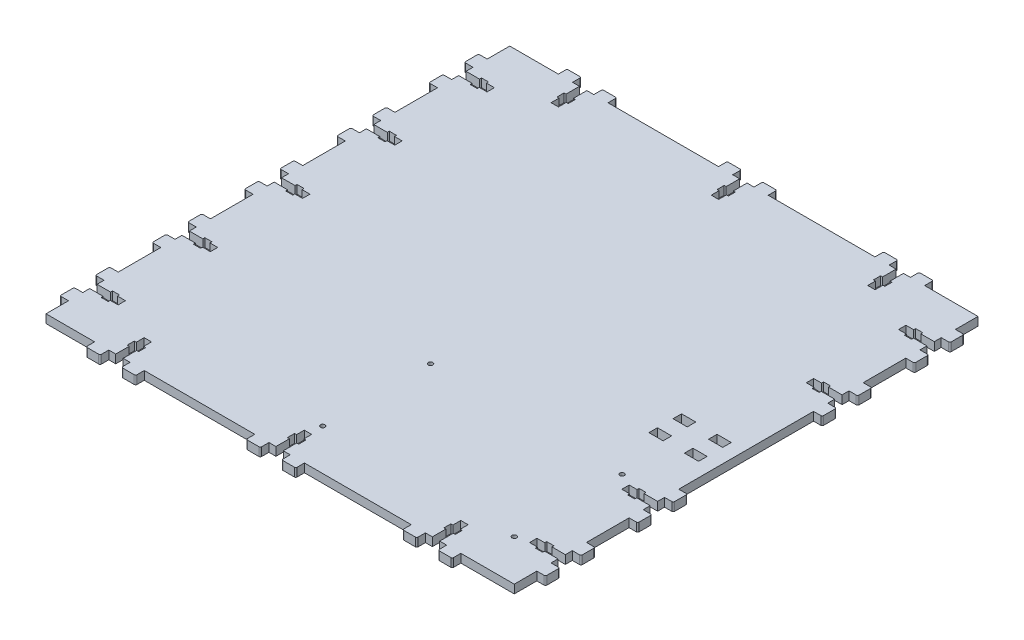
from build123d import *

# Parameters (mm, degrees)
SKETCH1_W                  = 330
SKETCH1_H                  = 326.8
BOSS_EXTRUDE1_DEPTH        = 6
CUT_EXTRUDE2_DEPTH         = 4
CUT_EXTRUDE2_DEPTH_BACK    = 4
SKETCH234_W                = 6.1
SKETCH234_H                = 10
BOSS_EXTRUDE2_DEPTH        = 3
BOSS_EXTRUDE2_DEPTH_BACK   = 3
FILLET1_R                  = 1
CUT_EXTRUDE21_DEPTH        = 4
CUT_EXTRUDE21_DEPTH_BACK   = 4
SKETCH2341_W               = 6.1
SKETCH2341_H               = 10
BOSS_EXTRUDE21_DEPTH       = 3
BOSS_EXTRUDE21_DEPTH_BACK  = 3
FILLET11_R                 = 1
CUT_EXTRUDE22_DEPTH        = 4
CUT_EXTRUDE22_DEPTH_BACK   = 4
SKETCH2342_W               = 6.1
SKETCH2342_H               = 10
BOSS_EXTRUDE22_DEPTH       = 3
BOSS_EXTRUDE22_DEPTH_BACK  = 3
FILLET12_R                 = 1
CUT_EXTRUDE23_DEPTH        = 4
CUT_EXTRUDE23_DEPTH_BACK   = 4
SKETCH2343_W               = 6.1
SKETCH2343_H               = 10
BOSS_EXTRUDE23_DEPTH       = 3
BOSS_EXTRUDE23_DEPTH_BACK  = 3
FILLET13_R                 = 1
CUT_EXTRUDE24_DEPTH        = 4
CUT_EXTRUDE24_DEPTH_BACK   = 4
SKETCH2344_W               = 6.1
SKETCH2344_H               = 10
BOSS_EXTRUDE24_DEPTH       = 3
BOSS_EXTRUDE24_DEPTH_BACK  = 3
FILLET14_R                 = 1
CUT_EXTRUDE25_DEPTH        = 4
CUT_EXTRUDE25_DEPTH_BACK   = 4
SKETCH2345_W               = 6.1
SKETCH2345_H               = 10
BOSS_EXTRUDE25_DEPTH       = 3
BOSS_EXTRUDE25_DEPTH_BACK  = 3
FILLET15_R                 = 1
CUT_EXTRUDE27_DEPTH        = 4
CUT_EXTRUDE27_DEPTH_BACK   = 4
SKETCH2347_W               = 6.1
SKETCH2347_H               = 10
BOSS_EXTRUDE27_DEPTH       = 3
BOSS_EXTRUDE27_DEPTH_BACK  = 3
FILLET17_R                 = 1
CUT_EXTRUDE28_DEPTH        = 4
CUT_EXTRUDE28_DEPTH_BACK   = 4
SKETCH2348_W               = 6.1
SKETCH2348_H               = 10
BOSS_EXTRUDE28_DEPTH       = 3
BOSS_EXTRUDE28_DEPTH_BACK  = 3
FILLET18_R                 = 1
CUT_EXTRUDE29_DEPTH        = 4
CUT_EXTRUDE29_DEPTH_BACK   = 4
SKETCH2349_W               = 6.1
SKETCH2349_H               = 10
BOSS_EXTRUDE29_DEPTH       = 3
BOSS_EXTRUDE29_DEPTH_BACK  = 3
FILLET19_R                 = 1
CUT_EXTRUDE210_DEPTH       = 4
CUT_EXTRUDE210_DEPTH_BACK  = 4
SKETCH23410_W              = 6.1
SKETCH23410_H              = 10
BOSS_EXTRUDE210_DEPTH      = 3
BOSS_EXTRUDE210_DEPTH_BACK = 3
FILLET110_R                = 1
CUT_EXTRUDE211_DEPTH       = 4
CUT_EXTRUDE211_DEPTH_BACK  = 4
SKETCH23411_W              = 6.1
SKETCH23411_H              = 10
BOSS_EXTRUDE211_DEPTH      = 3
BOSS_EXTRUDE211_DEPTH_BACK = 3
FILLET111_R                = 1
CUT_EXTRUDE213_DEPTH       = 4
CUT_EXTRUDE213_DEPTH_BACK  = 4
SKETCH23415_W              = 6.1
SKETCH23415_H              = 10
BOSS_EXTRUDE213_DEPTH      = 3
BOSS_EXTRUDE213_DEPTH_BACK = 3
FILLET113_R                = 1
CUT_EXTRUDE214_DEPTH       = 4
CUT_EXTRUDE214_DEPTH_BACK  = 4
SKETCH23416_W              = 6.1
SKETCH23416_H              = 10
BOSS_EXTRUDE214_DEPTH      = 3
BOSS_EXTRUDE214_DEPTH_BACK = 3
FILLET114_R                = 1
CUT_EXTRUDE216_DEPTH       = 4
CUT_EXTRUDE216_DEPTH_BACK  = 4
SKETCH23420_W              = 6.1
SKETCH23420_H              = 10
BOSS_EXTRUDE216_DEPTH      = 3
BOSS_EXTRUDE216_DEPTH_BACK = 3
FILLET116_R                = 1
CUT_EXTRUDE217_DEPTH       = 4
CUT_EXTRUDE217_DEPTH_BACK  = 4
SKETCH23422_W              = 6.1
SKETCH23422_H              = 10
BOSS_EXTRUDE217_DEPTH      = 3
BOSS_EXTRUDE217_DEPTH_BACK = 3
FILLET117_R                = 1
SKETCH6_W                  = 10
SKETCH6_H                  = 6
CUT_EXTRUDE1_DEPTH         = 4
SKETCH61_W                 = 10
SKETCH61_H                 = 6
CUT_EXTRUDE11_DEPTH        = 4
M3_CLEARANCE_HOLE1_D       = 3.2


with BuildPart() as part:
    # Sketch1 → Boss-Extrude1 (new body)
    with BuildSketch(Plane(origin=(0, 0, 0), x_dir=(1, 0, 0), z_dir=(0, 1, 0))):
        Rectangle(SKETCH1_W, SKETCH1_H)
    extrude(amount=BOSS_EXTRUDE1_DEPTH)

    # Sketch23 → Cut-Extrude2 (cut, two sides)
    with BuildSketch(Plane(origin=(-93.25, 3, 113.4), x_dir=(0, 0, 1), z_dir=(0, -1, 0))) as cut_extrude2_sk:
        Polygon((30, 17.4), (30, 22.6), (35.5, 22.6), (35.5, 24), (40.5, 24), (40.5, 22.6), (50, 22.6), (50, 17.4), (40.5, 17.4), (40.5, 16), (35.5, 16), (35.5, 17.4), align=None)
    extrude(amount=CUT_EXTRUDE2_DEPTH, mode=Mode.SUBTRACT)
    extrude(cut_extrude2_sk.sketch, amount=-CUT_EXTRUDE2_DEPTH_BACK, mode=Mode.SUBTRACT)

    # Sketch234 → Boss-Extrude2 (add, two sides)
    with BuildSketch(Plane(origin=(-93.25, 3, 113.4), x_dir=(0, 0, 1), z_dir=(0, -1, 0))) as boss_extrude2_sk:
        with Locations((53.05, 32.5)):
            Rectangle(SKETCH234_W, SKETCH234_H)
        with Locations((53.05, 7.5)):
            Rectangle(SKETCH234_W, SKETCH234_H)
    extrude(amount=BOSS_EXTRUDE2_DEPTH)
    extrude(boss_extrude2_sk.sketch, amount=-BOSS_EXTRUDE2_DEPTH_BACK)

    # Fillet1
    fillet1_edges = [part.edges().sort_by_distance(p)[0] for p in [
        (-130.75, 3, 169.5),
        (-120.75, 3, 169.5),
        (-105.75, 3, 169.5),
        (-95.75, 3, 169.5),
    ]]
    fillet(fillet1_edges, radius=FILLET1_R)

    # Sketch236 → Cut-Extrude21 (cut, two sides)
    with BuildSketch(Plane(origin=(19.625, 3, 113.4), x_dir=(0, 0, 1), z_dir=(0, -1, 0))) as cut_extrude21_sk:
        Polygon((30, 17.4), (30, 22.6), (35.5, 22.6), (35.5, 24), (40.5, 24), (40.5, 22.6), (50, 22.6), (50, 17.4), (40.5, 17.4), (40.5, 16), (35.5, 16), (35.5, 17.4), align=None)
    extrude(amount=CUT_EXTRUDE21_DEPTH, mode=Mode.SUBTRACT)
    extrude(cut_extrude21_sk.sketch, amount=-CUT_EXTRUDE21_DEPTH_BACK, mode=Mode.SUBTRACT)

    # Sketch2341 → Boss-Extrude21 (add, two sides)
    with BuildSketch(Plane(origin=(19.625, 3, 113.4), x_dir=(0, 0, 1), z_dir=(0, -1, 0))) as boss_extrude21_sk:
        with Locations((53.05, 32.5)):
            Rectangle(SKETCH2341_W, SKETCH2341_H)
        with Locations((53.05, 7.5)):
            Rectangle(SKETCH2341_W, SKETCH2341_H)
    extrude(amount=BOSS_EXTRUDE21_DEPTH)
    extrude(boss_extrude21_sk.sketch, amount=-BOSS_EXTRUDE21_DEPTH_BACK)

    # Fillet11
    fillet11_edges = [part.edges().sort_by_distance(p)[0] for p in [
        (-17.875, 3, 169.5),
        (-7.875, 3, 169.5),
        (7.125, 3, 169.5),
        (17.125, 3, 169.5),
    ]]
    fillet(fillet11_edges, radius=FILLET11_R)

    # Sketch237 → Cut-Extrude22 (cut, two sides)
    with BuildSketch(Plane(origin=(129.875, 3, 113.4), x_dir=(0, 0, 1), z_dir=(0, -1, 0))) as cut_extrude22_sk:
        Polygon((30, 17.4), (30, 22.6), (35.5, 22.6), (35.5, 24), (40.5, 24), (40.5, 22.6), (50, 22.6), (50, 17.4), (40.5, 17.4), (40.5, 16), (35.5, 16), (35.5, 17.4), align=None)
    extrude(amount=CUT_EXTRUDE22_DEPTH, mode=Mode.SUBTRACT)
    extrude(cut_extrude22_sk.sketch, amount=-CUT_EXTRUDE22_DEPTH_BACK, mode=Mode.SUBTRACT)

    # Sketch2342 → Boss-Extrude22 (add, two sides)
    with BuildSketch(Plane(origin=(129.875, 3, 113.4), x_dir=(0, 0, 1), z_dir=(0, -1, 0))) as boss_extrude22_sk:
        with Locations((53.05, 32.5)):
            Rectangle(SKETCH2342_W, SKETCH2342_H)
        with Locations((53.05, 7.5)):
            Rectangle(SKETCH2342_W, SKETCH2342_H)
    extrude(amount=BOSS_EXTRUDE22_DEPTH)
    extrude(boss_extrude22_sk.sketch, amount=-BOSS_EXTRUDE22_DEPTH_BACK)

    # Fillet12
    fillet12_edges = [part.edges().sort_by_distance(p)[0] for p in [
        (92.375, 3, 169.5),
        (102.375, 3, 169.5),
        (117.375, 3, 169.5),
        (127.375, 3, 169.5),
    ]]
    fillet(fillet12_edges, radius=FILLET12_R)

    # Sketch238 → Cut-Extrude23 (cut, two sides)
    with BuildSketch(Plane(origin=(-93.25, 3, -113.4), x_dir=(0, 0, -1), z_dir=(0, 1, 0))) as cut_extrude23_sk:
        Polygon((30, 17.4), (30, 22.6), (35.5, 22.6), (35.5, 24), (40.5, 24), (40.5, 22.6), (50, 22.6), (50, 17.4), (40.5, 17.4), (40.5, 16), (35.5, 16), (35.5, 17.4), align=None)
    extrude(amount=CUT_EXTRUDE23_DEPTH, mode=Mode.SUBTRACT)
    extrude(cut_extrude23_sk.sketch, amount=-CUT_EXTRUDE23_DEPTH_BACK, mode=Mode.SUBTRACT)

    # Sketch2343 → Boss-Extrude23 (add, two sides)
    with BuildSketch(Plane(origin=(-93.25, 3, -113.4), x_dir=(0, 0, -1), z_dir=(0, 1, 0))) as boss_extrude23_sk:
        with Locations((53.05, 32.5)):
            Rectangle(SKETCH2343_W, SKETCH2343_H)
        with Locations((53.05, 7.5)):
            Rectangle(SKETCH2343_W, SKETCH2343_H)
    extrude(amount=BOSS_EXTRUDE23_DEPTH)
    extrude(boss_extrude23_sk.sketch, amount=-BOSS_EXTRUDE23_DEPTH_BACK)

    # Fillet13
    fillet13_edges = [part.edges().sort_by_distance(p)[0] for p in [
        (-130.75, 3, -169.5),
        (-120.75, 3, -169.5),
        (-105.75, 3, -169.5),
        (-95.75, 3, -169.5),
    ]]
    fillet(fillet13_edges, radius=FILLET13_R)

    # Sketch239 → Cut-Extrude24 (cut, two sides)
    with BuildSketch(Plane(origin=(19.625, 3, -113.4), x_dir=(0, 0, -1), z_dir=(0, 1, 0))) as cut_extrude24_sk:
        Polygon((30, 17.4), (30, 22.6), (35.5, 22.6), (35.5, 24), (40.5, 24), (40.5, 22.6), (50, 22.6), (50, 17.4), (40.5, 17.4), (40.5, 16), (35.5, 16), (35.5, 17.4), align=None)
    extrude(amount=CUT_EXTRUDE24_DEPTH, mode=Mode.SUBTRACT)
    extrude(cut_extrude24_sk.sketch, amount=-CUT_EXTRUDE24_DEPTH_BACK, mode=Mode.SUBTRACT)

    # Sketch2344 → Boss-Extrude24 (add, two sides)
    with BuildSketch(Plane(origin=(19.625, 3, -113.4), x_dir=(0, 0, -1), z_dir=(0, 1, 0))) as boss_extrude24_sk:
        with Locations((53.05, 32.5)):
            Rectangle(SKETCH2344_W, SKETCH2344_H)
        with Locations((53.05, 7.5)):
            Rectangle(SKETCH2344_W, SKETCH2344_H)
    extrude(amount=BOSS_EXTRUDE24_DEPTH)
    extrude(boss_extrude24_sk.sketch, amount=-BOSS_EXTRUDE24_DEPTH_BACK)

    # Fillet14
    fillet14_edges = [part.edges().sort_by_distance(p)[0] for p in [
        (-17.875, 3, -169.5),
        (-7.875, 3, -169.5),
        (7.125, 3, -169.5),
        (17.125, 3, -169.5),
    ]]
    fillet(fillet14_edges, radius=FILLET14_R)

    # Sketch2310 → Cut-Extrude25 (cut, two sides)
    with BuildSketch(Plane(origin=(129.875, 3, -113.4), x_dir=(0, 0, -1), z_dir=(0, 1, 0))) as cut_extrude25_sk:
        Polygon((30, 17.4), (30, 22.6), (35.5, 22.6), (35.5, 24), (40.5, 24), (40.5, 22.6), (50, 22.6), (50, 17.4), (40.5, 17.4), (40.5, 16), (35.5, 16), (35.5, 17.4), align=None)
    extrude(amount=CUT_EXTRUDE25_DEPTH, mode=Mode.SUBTRACT)
    extrude(cut_extrude25_sk.sketch, amount=-CUT_EXTRUDE25_DEPTH_BACK, mode=Mode.SUBTRACT)

    # Sketch2345 → Boss-Extrude25 (add, two sides)
    with BuildSketch(Plane(origin=(129.875, 3, -113.4), x_dir=(0, 0, -1), z_dir=(0, 1, 0))) as boss_extrude25_sk:
        with Locations((53.05, 32.5)):
            Rectangle(SKETCH2345_W, SKETCH2345_H)
        with Locations((53.05, 7.5)):
            Rectangle(SKETCH2345_W, SKETCH2345_H)
    extrude(amount=BOSS_EXTRUDE25_DEPTH)
    extrude(boss_extrude25_sk.sketch, amount=-BOSS_EXTRUDE25_DEPTH_BACK)

    # Fillet15
    fillet15_edges = [part.edges().sort_by_distance(p)[0] for p in [
        (92.375, 3, -169.5),
        (102.375, 3, -169.5),
        (117.375, 3, -169.5),
        (127.375, 3, -169.5),
    ]]
    fillet(fillet15_edges, radius=FILLET15_R)

    # Sketch2312 → Cut-Extrude27 (cut, two sides)
    with BuildSketch(Plane(origin=(-115, 3, 110), x_dir=(-1, 0, 0), z_dir=(0, 1, 0))) as cut_extrude27_sk:
        Polygon((30, 17.4), (30, 22.6), (35.5, 22.6), (35.5, 24), (40.5, 24), (40.5, 22.6), (50, 22.6), (50, 17.4), (40.5, 17.4), (40.5, 16), (35.5, 16), (35.5, 17.4), align=None)
    extrude(amount=CUT_EXTRUDE27_DEPTH, mode=Mode.SUBTRACT)
    extrude(cut_extrude27_sk.sketch, amount=-CUT_EXTRUDE27_DEPTH_BACK, mode=Mode.SUBTRACT)

    # Sketch2347 → Boss-Extrude27 (add, two sides)
    with BuildSketch(Plane(origin=(-115, 3, 110), x_dir=(-1, 0, 0), z_dir=(0, 1, 0))) as boss_extrude27_sk:
        with Locations((53.05, 32.5)):
            Rectangle(SKETCH2347_W, SKETCH2347_H)
        with Locations((53.05, 7.5)):
            Rectangle(SKETCH2347_W, SKETCH2347_H)
    extrude(amount=BOSS_EXTRUDE27_DEPTH)
    extrude(boss_extrude27_sk.sketch, amount=-BOSS_EXTRUDE27_DEPTH_BACK)

    # Fillet17
    fillet17_edges = [part.edges().sort_by_distance(p)[0] for p in [
        (-171.1, 3, 147.5),
        (-171.1, 3, 137.5),
        (-171.1, 3, 122.5),
        (-171.1, 3, 112.5),
    ]]
    fillet(fillet17_edges, radius=FILLET17_R)

    # Sketch2313 → Cut-Extrude28 (cut, two sides)
    with BuildSketch(Plane(origin=(-115, 3, 45), x_dir=(-1, 0, 0), z_dir=(0, 1, 0))) as cut_extrude28_sk:
        Polygon((30, 17.4), (30, 22.6), (35.5, 22.6), (35.5, 24), (40.5, 24), (40.5, 22.6), (50, 22.6), (50, 17.4), (40.5, 17.4), (40.5, 16), (35.5, 16), (35.5, 17.4), align=None)
    extrude(amount=CUT_EXTRUDE28_DEPTH, mode=Mode.SUBTRACT)
    extrude(cut_extrude28_sk.sketch, amount=-CUT_EXTRUDE28_DEPTH_BACK, mode=Mode.SUBTRACT)

    # Sketch2348 → Boss-Extrude28 (add, two sides)
    with BuildSketch(Plane(origin=(-115, 3, 45), x_dir=(-1, 0, 0), z_dir=(0, 1, 0))) as boss_extrude28_sk:
        with Locations((53.05, 32.5)):
            Rectangle(SKETCH2348_W, SKETCH2348_H)
        with Locations((53.05, 7.5)):
            Rectangle(SKETCH2348_W, SKETCH2348_H)
    extrude(amount=BOSS_EXTRUDE28_DEPTH)
    extrude(boss_extrude28_sk.sketch, amount=-BOSS_EXTRUDE28_DEPTH_BACK)

    # Fillet18
    fillet18_edges = [part.edges().sort_by_distance(p)[0] for p in [
        (-171.1, 3, 82.5),
        (-171.1, 3, 72.5),
        (-171.1, 3, 57.5),
        (-171.1, 3, 47.5),
    ]]
    fillet(fillet18_edges, radius=FILLET18_R)

    # Sketch2314 → Cut-Extrude29 (cut, two sides)
    with BuildSketch(Plane(origin=(-115, 3, -20), x_dir=(-1, 0, 0), z_dir=(0, 1, 0))) as cut_extrude29_sk:
        Polygon((30, 17.4), (30, 22.6), (35.5, 22.6), (35.5, 24), (40.5, 24), (40.5, 22.6), (50, 22.6), (50, 17.4), (40.5, 17.4), (40.5, 16), (35.5, 16), (35.5, 17.4), align=None)
    extrude(amount=CUT_EXTRUDE29_DEPTH, mode=Mode.SUBTRACT)
    extrude(cut_extrude29_sk.sketch, amount=-CUT_EXTRUDE29_DEPTH_BACK, mode=Mode.SUBTRACT)

    # Sketch2349 → Boss-Extrude29 (add, two sides)
    with BuildSketch(Plane(origin=(-115, 3, -20), x_dir=(-1, 0, 0), z_dir=(0, 1, 0))) as boss_extrude29_sk:
        with Locations((53.05, 32.5)):
            Rectangle(SKETCH2349_W, SKETCH2349_H)
        with Locations((53.05, 7.5)):
            Rectangle(SKETCH2349_W, SKETCH2349_H)
    extrude(amount=BOSS_EXTRUDE29_DEPTH)
    extrude(boss_extrude29_sk.sketch, amount=-BOSS_EXTRUDE29_DEPTH_BACK)

    # Fillet19
    fillet19_edges = [part.edges().sort_by_distance(p)[0] for p in [
        (-171.1, 3, 17.5),
        (-171.1, 3, 7.5),
        (-171.1, 3, -7.5),
        (-171.1, 3, -17.5),
    ]]
    fillet(fillet19_edges, radius=FILLET19_R)

    # Sketch2315 → Cut-Extrude210 (cut, two sides)
    with BuildSketch(Plane(origin=(-115, 3, -85), x_dir=(-1, 0, 0), z_dir=(0, 1, 0))) as cut_extrude210_sk:
        Polygon((30, 17.4), (30, 22.6), (35.5, 22.6), (35.5, 24), (40.5, 24), (40.5, 22.6), (50, 22.6), (50, 17.4), (40.5, 17.4), (40.5, 16), (35.5, 16), (35.5, 17.4), align=None)
    extrude(amount=CUT_EXTRUDE210_DEPTH, mode=Mode.SUBTRACT)
    extrude(cut_extrude210_sk.sketch, amount=-CUT_EXTRUDE210_DEPTH_BACK, mode=Mode.SUBTRACT)

    # Sketch23410 → Boss-Extrude210 (add, two sides)
    with BuildSketch(Plane(origin=(-115, 3, -85), x_dir=(-1, 0, 0), z_dir=(0, 1, 0))) as boss_extrude210_sk:
        with Locations((53.05, 32.5)):
            Rectangle(SKETCH23410_W, SKETCH23410_H)
        with Locations((53.05, 7.5)):
            Rectangle(SKETCH23410_W, SKETCH23410_H)
    extrude(amount=BOSS_EXTRUDE210_DEPTH)
    extrude(boss_extrude210_sk.sketch, amount=-BOSS_EXTRUDE210_DEPTH_BACK)

    # Fillet110
    fillet110_edges = [part.edges().sort_by_distance(p)[0] for p in [
        (-171.1, 3, -47.5),
        (-171.1, 3, -57.5),
        (-171.1, 3, -72.5),
        (-171.1, 3, -82.5),
    ]]
    fillet(fillet110_edges, radius=FILLET110_R)

    # Sketch2316 → Cut-Extrude211 (cut, two sides)
    with BuildSketch(Plane(origin=(-115, 3, -150), x_dir=(-1, 0, 0), z_dir=(0, 1, 0))) as cut_extrude211_sk:
        Polygon((30, 17.4), (30, 22.6), (35.5, 22.6), (35.5, 24), (40.5, 24), (40.5, 22.6), (50, 22.6), (50, 17.4), (40.5, 17.4), (40.5, 16), (35.5, 16), (35.5, 17.4), align=None)
    extrude(amount=CUT_EXTRUDE211_DEPTH, mode=Mode.SUBTRACT)
    extrude(cut_extrude211_sk.sketch, amount=-CUT_EXTRUDE211_DEPTH_BACK, mode=Mode.SUBTRACT)

    # Sketch23411 → Boss-Extrude211 (add, two sides)
    with BuildSketch(Plane(origin=(-115, 3, -150), x_dir=(-1, 0, 0), z_dir=(0, 1, 0))) as boss_extrude211_sk:
        with Locations((53.05, 32.5)):
            Rectangle(SKETCH23411_W, SKETCH23411_H)
        with Locations((53.05, 7.5)):
            Rectangle(SKETCH23411_W, SKETCH23411_H)
    extrude(amount=BOSS_EXTRUDE211_DEPTH)
    extrude(boss_extrude211_sk.sketch, amount=-BOSS_EXTRUDE211_DEPTH_BACK)

    # Fillet111
    fillet111_edges = [part.edges().sort_by_distance(p)[0] for p in [
        (-171.1, 3, -112.5),
        (-171.1, 3, -122.5),
        (-171.1, 3, -137.5),
        (-171.1, 3, -147.5),
    ]]
    fillet(fillet111_edges, radius=FILLET111_R)

    # Sketch23413 → Cut-Extrude213 (cut, two sides)
    with BuildSketch(Plane(origin=(115, 3, 150), x_dir=(1, 0, 0), z_dir=(0, 1, 0))) as cut_extrude213_sk:
        Polygon((30, 17.4), (30, 22.6), (35.5, 22.6), (35.5, 24), (40.5, 24), (40.5, 22.6), (50, 22.6), (50, 17.4), (40.5, 17.4), (40.5, 16), (35.5, 16), (35.5, 17.4), align=None)
    extrude(amount=CUT_EXTRUDE213_DEPTH, mode=Mode.SUBTRACT)
    extrude(cut_extrude213_sk.sketch, amount=-CUT_EXTRUDE213_DEPTH_BACK, mode=Mode.SUBTRACT)

    # Sketch23415 → Boss-Extrude213 (add, two sides)
    with BuildSketch(Plane(origin=(115, 3, 150), x_dir=(1, 0, 0), z_dir=(0, 1, 0))) as boss_extrude213_sk:
        with Locations((53.05, 32.5)):
            Rectangle(SKETCH23415_W, SKETCH23415_H)
        with Locations((53.05, 7.5)):
            Rectangle(SKETCH23415_W, SKETCH23415_H)
    extrude(amount=BOSS_EXTRUDE213_DEPTH)
    extrude(boss_extrude213_sk.sketch, amount=-BOSS_EXTRUDE213_DEPTH_BACK)

    # Fillet113
    fillet113_edges = [part.edges().sort_by_distance(p)[0] for p in [
        (171.1, 3, 112.5),
        (171.1, 3, 122.5),
        (171.1, 3, 137.5),
        (171.1, 3, 147.5),
    ]]
    fillet(fillet113_edges, radius=FILLET113_R)

    # Sketch23414 → Cut-Extrude214 (cut, two sides)
    with BuildSketch(Plane(origin=(115, 3, 45), x_dir=(1, 0, 0), z_dir=(0, -1, 0))) as cut_extrude214_sk:
        Polygon((30, 17.4), (30, 22.6), (35.5, 22.6), (35.5, 24), (40.5, 24), (40.5, 22.6), (50, 22.6), (50, 17.4), (40.5, 17.4), (40.5, 16), (35.5, 16), (35.5, 17.4), align=None)
    extrude(amount=CUT_EXTRUDE214_DEPTH, mode=Mode.SUBTRACT)
    extrude(cut_extrude214_sk.sketch, amount=-CUT_EXTRUDE214_DEPTH_BACK, mode=Mode.SUBTRACT)

    # Sketch23416 → Boss-Extrude214 (add, two sides)
    with BuildSketch(Plane(origin=(115, 3, 45), x_dir=(1, 0, 0), z_dir=(0, -1, 0))) as boss_extrude214_sk:
        with Locations((53.05, 32.5)):
            Rectangle(SKETCH23416_W, SKETCH23416_H)
        with Locations((53.05, 7.5)):
            Rectangle(SKETCH23416_W, SKETCH23416_H)
    extrude(amount=BOSS_EXTRUDE214_DEPTH)
    extrude(boss_extrude214_sk.sketch, amount=-BOSS_EXTRUDE214_DEPTH_BACK)

    # Fillet114
    fillet114_edges = [part.edges().sort_by_distance(p)[0] for p in [
        (171.1, 3, 82.5),
        (171.1, 3, 72.5),
        (171.1, 3, 57.5),
        (171.1, 3, 47.5),
    ]]
    fillet(fillet114_edges, radius=FILLET114_R)

    # Sketch23419 → Cut-Extrude216 (cut, two sides)
    with BuildSketch(Plane(origin=(115, 3, -85), x_dir=(1, 0, 0), z_dir=(0, -1, 0))) as cut_extrude216_sk:
        Polygon((30, 17.4), (30, 22.6), (35.5, 22.6), (35.5, 24), (40.5, 24), (40.5, 22.6), (50, 22.6), (50, 17.4), (40.5, 17.4), (40.5, 16), (35.5, 16), (35.5, 17.4), align=None)
    extrude(amount=CUT_EXTRUDE216_DEPTH, mode=Mode.SUBTRACT)
    extrude(cut_extrude216_sk.sketch, amount=-CUT_EXTRUDE216_DEPTH_BACK, mode=Mode.SUBTRACT)

    # Sketch23420 → Boss-Extrude216 (add, two sides)
    with BuildSketch(Plane(origin=(115, 3, -85), x_dir=(1, 0, 0), z_dir=(0, -1, 0))) as boss_extrude216_sk:
        with Locations((53.05, 32.5)):
            Rectangle(SKETCH23420_W, SKETCH23420_H)
        with Locations((53.05, 7.5)):
            Rectangle(SKETCH23420_W, SKETCH23420_H)
    extrude(amount=BOSS_EXTRUDE216_DEPTH)
    extrude(boss_extrude216_sk.sketch, amount=-BOSS_EXTRUDE216_DEPTH_BACK)

    # Fillet116
    fillet116_edges = [part.edges().sort_by_distance(p)[0] for p in [
        (171.1, 3, -47.5),
        (171.1, 3, -57.5),
        (171.1, 3, -72.5),
        (171.1, 3, -82.5),
    ]]
    fillet(fillet116_edges, radius=FILLET116_R)

    # Sketch23421 → Cut-Extrude217 (cut, two sides)
    with BuildSketch(Plane(origin=(115, 3, -150), x_dir=(1, 0, 0), z_dir=(0, -1, 0))) as cut_extrude217_sk:
        Polygon((30, 17.4), (30, 22.6), (35.5, 22.6), (35.5, 24), (40.5, 24), (40.5, 22.6), (50, 22.6), (50, 17.4), (40.5, 17.4), (40.5, 16), (35.5, 16), (35.5, 17.4), align=None)
    extrude(amount=CUT_EXTRUDE217_DEPTH, mode=Mode.SUBTRACT)
    extrude(cut_extrude217_sk.sketch, amount=-CUT_EXTRUDE217_DEPTH_BACK, mode=Mode.SUBTRACT)

    # Sketch23422 → Boss-Extrude217 (add, two sides)
    with BuildSketch(Plane(origin=(115, 3, -150), x_dir=(1, 0, 0), z_dir=(0, -1, 0))) as boss_extrude217_sk:
        with Locations((53.05, 32.5)):
            Rectangle(SKETCH23422_W, SKETCH23422_H)
        with Locations((53.05, 7.5)):
            Rectangle(SKETCH23422_W, SKETCH23422_H)
    extrude(amount=BOSS_EXTRUDE217_DEPTH)
    extrude(boss_extrude217_sk.sketch, amount=-BOSS_EXTRUDE217_DEPTH_BACK)

    # Fillet117
    fillet117_edges = [part.edges().sort_by_distance(p)[0] for p in [
        (171.1, 3, -112.5),
        (171.1, 3, -122.5),
        (171.1, 3, -137.5),
        (171.1, 3, -147.5),
    ]]
    fillet(fillet117_edges, radius=FILLET117_R)

    # Sketch6 → Cut-Extrude1 (cut, symmetric)
    with BuildSketch(Plane(origin=(149.232221392, 3, 47.5), x_dir=(1, 0, 0), z_dir=(0, -1, 0))):
        with Locations((0.767778608, -44)):
            Rectangle(SKETCH6_W, SKETCH6_H)
    cut_extrude1 = extrude(amount=CUT_EXTRUDE1_DEPTH, both=True, mode=Mode.SUBTRACT)

    # Sketch61 → Cut-Extrude11 (cut, symmetric)
    with BuildSketch(Plane(origin=(125.767778608, 3, -40.5), x_dir=(-1, 0, 0), z_dir=(0, -1, 0))):
        with Locations((0.767778608, -44)):
            Rectangle(SKETCH61_W, SKETCH61_H)
    cut_extrude11 = extrude(amount=CUT_EXTRUDE11_DEPTH, both=True, mode=Mode.SUBTRACT)

    # Mirror1: Cut-Extrude1, Cut-Extrude11 across plane
    add(cut_extrude1.mirror(Plane.XY.offset(12)), mode=Mode.SUBTRACT)
    add(cut_extrude11.mirror(Plane.XY.offset(12)), mode=Mode.SUBTRACT)

    # M3 Clearance Hole1 (through all)
    with Locations(Plane(origin=(0, 6, 0), x_dir=(1, 0, 0), z_dir=(0, 1, 0))):
        with Locations((136, -134.4), (136, -58.4), (1, -134.4), (1, -58.4)):
            Hole(M3_CLEARANCE_HOLE1_D / 2)


solid = part.part
